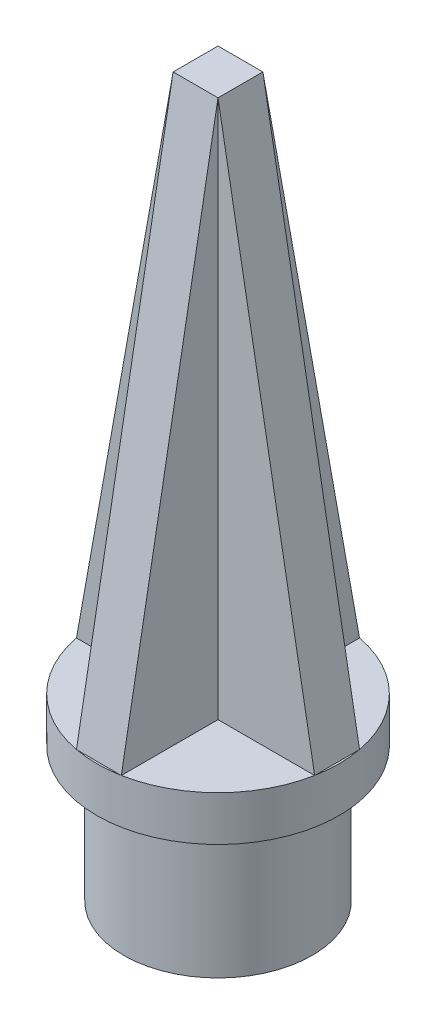
from build123d import *

# Parameters (mm, degrees)
SKETCH1_R           = 10.5
BOSS_EXTRUDE1_DEPTH = 15
SKETCH6_R           = 13.5
BOSS_EXTRUDE4_DEPTH = 5
BOSS_EXTRUDE6_DEPTH = 60
SKETCH10_R          = 7.5
CUT_EXTRUDE5_DEPTH  = 15
CUT_EXTRUDE6_REACH  = 18
CUT_EXTRUDE7_REACH  = 18


with BuildPart() as part:
    # Sketch1 → Boss-Extrude1 (new body)
    with BuildSketch(Plane(origin=(0, 0, 0), x_dir=(1, 0, 0), z_dir=(0, 1, 0))):
        Circle(SKETCH1_R)
    extrude(amount=BOSS_EXTRUDE1_DEPTH)

    # Sketch6 → Boss-Extrude4 (add)
    with BuildSketch(Plane(origin=(0, 15, 0), x_dir=(1, 0, 0), z_dir=(0, 1, 0))):
        Circle(SKETCH6_R)
    extrude(amount=BOSS_EXTRUDE4_DEPTH)

    # Sketch12 → Boss-Extrude6 (add)
    with BuildSketch(Plane(origin=(0, 20, 0), x_dir=(1, 0, 0), z_dir=(0, 1, 0))):
        Polygon((2.5, -2.5), (13.266499161, -2.5), (13.266499161, 2.5), (2.5, 2.5), (2.5, 13.266499161), (-2.5, 13.266499161), (-2.5, 2.5), (-13.266499161, 2.5), (-13.266499161, -2.5), (-2.5, -2.5), (-2.5, -13.266499161), (2.5, -13.266499161), align=None)
    extrude(amount=BOSS_EXTRUDE6_DEPTH)

    # Sketch10 → Cut-Extrude5 (cut)
    with BuildSketch(Plane.XZ):
        Circle(SKETCH10_R)
    extrude(amount=-CUT_EXTRUDE5_DEPTH, mode=Mode.SUBTRACT)

    # Sketch17 → Cut-Extrude6 (cut, up to next)
    with BuildSketch(Plane.ZY.offset(2.5), mode=Mode.PRIVATE) as cut_extrude6_sk1:
        Polygon((-13.266499161, 80), (-13.266499161, 20), (-2.5, 80), align=None)
    cut_extrude6_tool1 = extrude(cut_extrude6_sk1.sketch, amount=-CUT_EXTRUDE6_REACH, mode=Mode.PRIVATE) & part.part
    add(cut_extrude6_tool1.solids().sort_by_distance((-2.5, 60, -9.677666))[0], mode=Mode.SUBTRACT)
    # Sketch17 → Cut-Extrude6 (cut, up to next)
    with BuildSketch(Plane.ZY.offset(2.5), mode=Mode.PRIVATE) as cut_extrude6_sk2:
        Polygon((2.5, 80), (13.266499161, 20), (13.266499161, 80), align=None)
    cut_extrude6_tool2 = extrude(cut_extrude6_sk2.sketch, amount=-CUT_EXTRUDE6_REACH, mode=Mode.PRIVATE) & part.part
    add(cut_extrude6_tool2.solids().sort_by_distance((-2.5, 60, 9.677666))[0], mode=Mode.SUBTRACT)

    # Sketch18 → Cut-Extrude7 (cut, up to next)
    with BuildSketch(Plane(origin=(0, 0, -2.5), x_dir=(-1, 0, 0), z_dir=(0, 0, -1)), mode=Mode.PRIVATE) as cut_extrude7_sk1:
        Polygon((2.5, 80), (13.266499161, 20), (13.266499161, 66.486374955), (13.266499161, 80), align=None)
    cut_extrude7_tool1 = extrude(cut_extrude7_sk1.sketch, amount=-CUT_EXTRUDE7_REACH, mode=Mode.PRIVATE) & part.part
    add(cut_extrude7_tool1.solids().sort_by_distance((-9.677666, 60, -2.5))[0], mode=Mode.SUBTRACT)
    # Sketch18 → Cut-Extrude7 (cut, up to next)
    with BuildSketch(Plane(origin=(0, 0, -2.5), x_dir=(-1, 0, 0), z_dir=(0, 0, -1)), mode=Mode.PRIVATE) as cut_extrude7_sk2:
        Polygon((-2.5, 80), (-13.266499161, 20), (-13.266499161, 80), align=None)
    cut_extrude7_tool2 = extrude(cut_extrude7_sk2.sketch, amount=-CUT_EXTRUDE7_REACH, mode=Mode.PRIVATE) & part.part
    add(cut_extrude7_tool2.solids().sort_by_distance((9.677666, 60, -2.5))[0], mode=Mode.SUBTRACT)


solid = part.part
